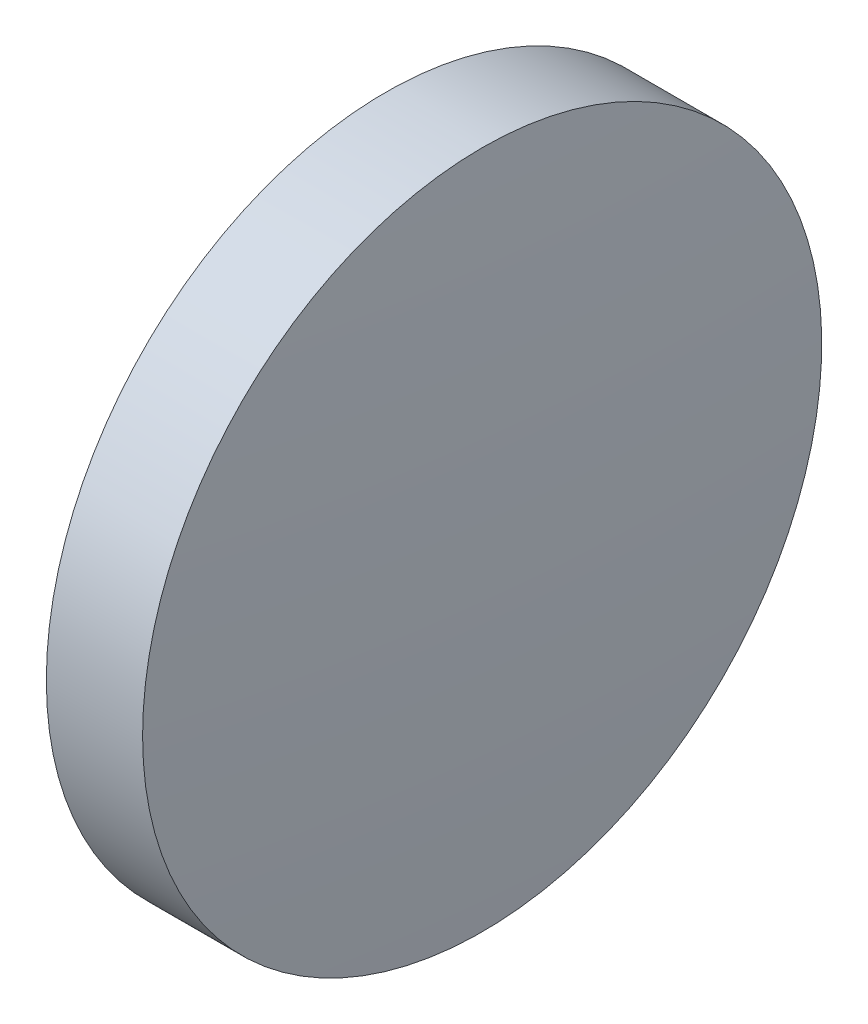
from build123d import *


with BuildPart() as part:
    # 草图1 → 旋转1 (revolve)
    with BuildSketch(Plane.XY):
        with BuildLine():
            Line((115.764555476, 65.233554926), (115.764555476, 77.933554926))
            Line((115.764555476, 77.933554926), (119.364555476, 77.933554926))
            ThreePointArc((119.364555476, 77.933554926), (119.664530688, 71.586703752), (119.764555476, 65.233554926))
            Line((119.764555476, 65.233554926), (115.764555476, 65.233554926))
        make_face()
    revolve(axis=Axis((110.165373228, 65.233554926, 0), (1, 0, 0)))


solid = part.part
